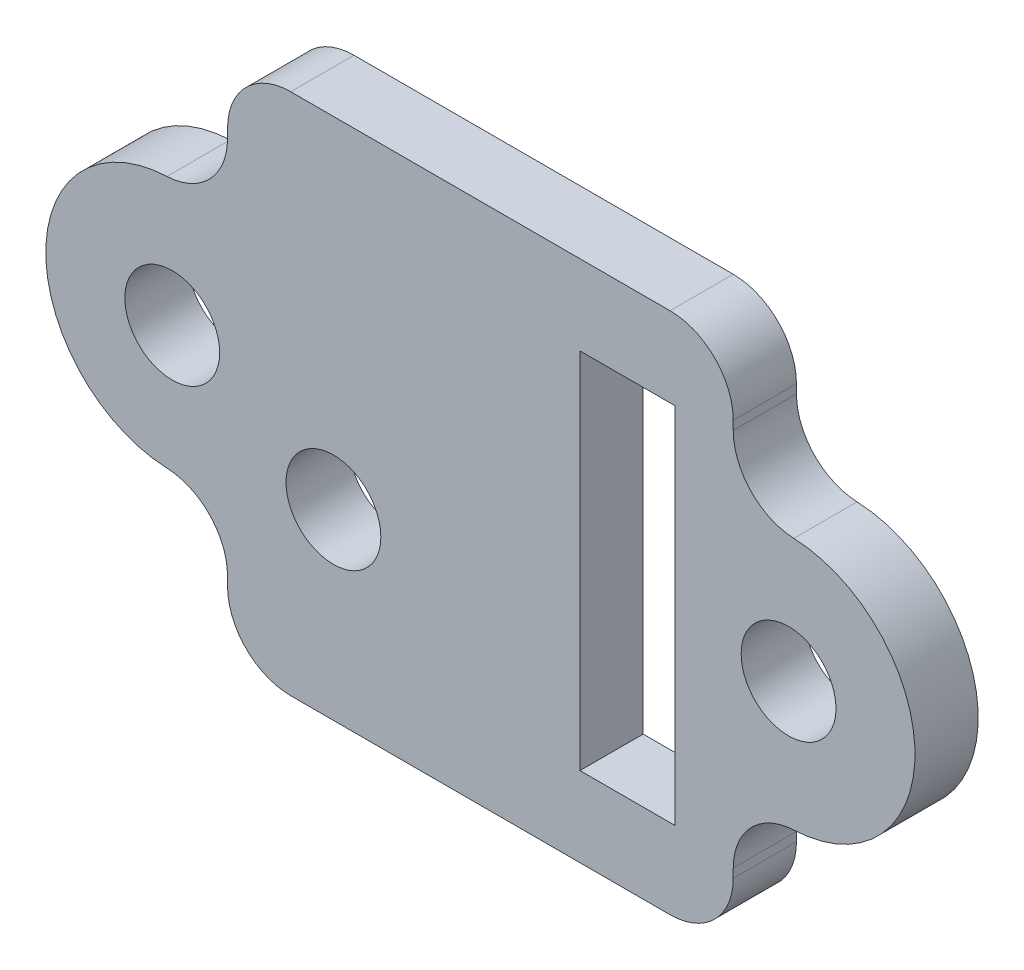
from build123d import *

# Parameters (mm, degrees)
SKETCH1_W               = 16
SKETCH1_H               = 16.55
BOSS_EXTRUDE1_DEPTH     = 1
SKETCH2_R               = 1.5
BOSS_EXTRUDE2_DEPTH     = 1
SKETCH3_R               = 1.5
SKETCH3_W               = 3
SKETCH3_H               = 11.5
CUT_EXTRUDE1_DEPTH      = 2
CUT_EXTRUDE1_DEPTH_BACK = 2
FILLET1_R               = 2


with BuildPart() as part:
    # Sketch1 → Boss-Extrude1 (new body, symmetric)
    with BuildSketch(Plane.XY):
        Rectangle(SKETCH1_W, SKETCH1_H)
    extrude(amount=BOSS_EXTRUDE1_DEPTH, both=True)

    # Sketch2 → Boss-Extrude2 (add, symmetric)
    with BuildSketch(Plane.XY):
        with BuildLine():
            Line((-9.75, 4), (-8, 4))
            Line((-8, 4), (-8, -4))
            Line((-8, -4), (-9.75, -4))
            ThreePointArc((-9.75, -4), (-13.75, 0), (-9.75, 4))
        make_face()
        with Locations((-9.75, 0)):
            Circle(SKETCH2_R, mode=Mode.SUBTRACT)
        with BuildLine():
            Line((9.75, -4), (8, -4))
            Line((8, -4), (8, 4))
            Line((8, 4), (9.75, 4))
            ThreePointArc((9.75, 4), (13.75, 0), (9.75, -4))
        make_face()
        with Locations((9.75, 0)):
            Circle(SKETCH2_R, mode=Mode.SUBTRACT)
    extrude(amount=BOSS_EXTRUDE2_DEPTH, both=True)

    # Sketch3 → Cut-Extrude1 (cut, two sides)
    with BuildSketch(Plane.XY) as cut_extrude1_sk:
        with Locations((-4.65, -2.5)):
            Circle(SKETCH3_R)
        with Locations((4.65, 0)):
            Rectangle(SKETCH3_W, SKETCH3_H)
    extrude(amount=CUT_EXTRUDE1_DEPTH, mode=Mode.SUBTRACT)
    extrude(cut_extrude1_sk.sketch, amount=-CUT_EXTRUDE1_DEPTH_BACK, mode=Mode.SUBTRACT)

    # Fillet1
    fillet1_edges = [part.edges().sort_by_distance(p)[0] for p in [
        (-8, -8.275, 0),
        (-8, -4, 0),
        (8, -8.275, 0),
        (8, -4, 0),
        (8, 4, 0),
        (8, 8.275, 0),
        (-8, 8.275, 0),
        (-8, 4, 0),
    ]]
    fillet(fillet1_edges, radius=FILLET1_R)


solid = part.part
